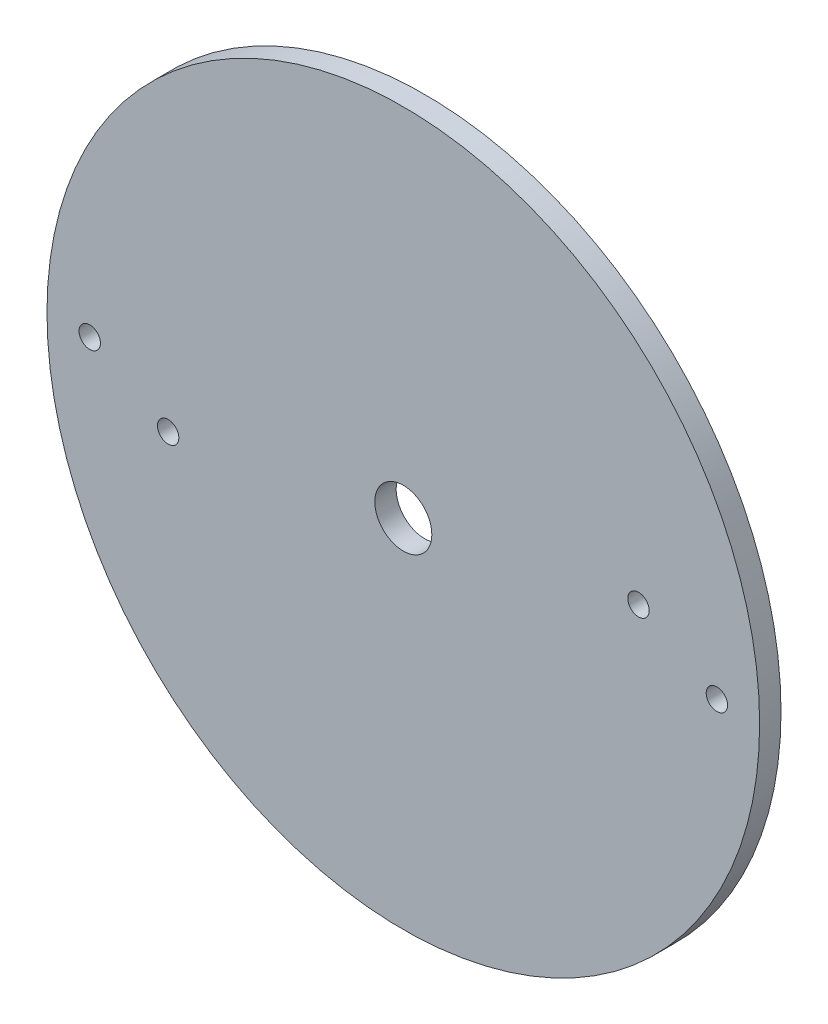
from build123d import *

# Parameters (mm, degrees)
ESQUISSE1_R             = 50
BOSS_EXTRU_1_DEPTH      = 3
ESQUISSE2_R             = 4
ENL_V_MAT_EXTRU_1_DEPTH = 3
ESQUISSE3_R             = 1.5
ENL_V_MAT_EXTRU_2_DEPTH = 3
R_P_T_PAR_COURBE1_COUNT = 2
ESQUISSE4_R             = 1.5
ENL_V_MAT_EXTRU_3_DEPTH = 3
R_P_T_PAR_COURBE2_COUNT = 2


with BuildPart() as part:
    # Esquisse1 → Boss.-Extru.1 (new body)
    with BuildSketch(Plane.XY):
        Circle(ESQUISSE1_R)
    extrude(amount=BOSS_EXTRU_1_DEPTH)

    # Esquisse2 → Enlèv. mat.-Extru.1 (cut)
    with BuildSketch(Plane.XY.offset(3)):
        Circle(ESQUISSE2_R)
    extrude(amount=-ENL_V_MAT_EXTRU_1_DEPTH, mode=Mode.SUBTRACT)

    # Esquisse3 → Enlèv. mat.-Extru.2 (cut)
    with BuildSketch(Plane.XY.offset(3)):
        with Locations((-44, 0)):
            Circle(ESQUISSE3_R)
    enl_v_mat_extru_2 = extrude(amount=-ENL_V_MAT_EXTRU_2_DEPTH, mode=Mode.SUBTRACT)

    # Répét. par courbe1: Enlèv. mat.-Extru.2 ×2 about axis
    r_p_t_par_courbe1_axis = Axis((0, 0, 3), (0, 0, 1))
    for i in range(1, R_P_T_PAR_COURBE1_COUNT):
        add(enl_v_mat_extru_2.rotate(r_p_t_par_courbe1_axis, i * 360 / R_P_T_PAR_COURBE1_COUNT), mode=Mode.SUBTRACT)

    # Esquisse4 → Enlèv. mat.-Extru.3 (cut)
    with BuildSketch(Plane.XY.offset(3)):
        with Locations((-33, -6)):
            Circle(ESQUISSE4_R)
    enl_v_mat_extru_3 = extrude(amount=-ENL_V_MAT_EXTRU_3_DEPTH, mode=Mode.SUBTRACT)

    # Répét. par courbe2: Enlèv. mat.-Extru.3 ×2 about axis
    r_p_t_par_courbe2_axis = Axis((0, 0, 3), (0, 0, 1))
    for i in range(1, R_P_T_PAR_COURBE2_COUNT):
        add(enl_v_mat_extru_3.rotate(r_p_t_par_courbe2_axis, i * 360 / R_P_T_PAR_COURBE2_COUNT), mode=Mode.SUBTRACT)


solid = part.part
